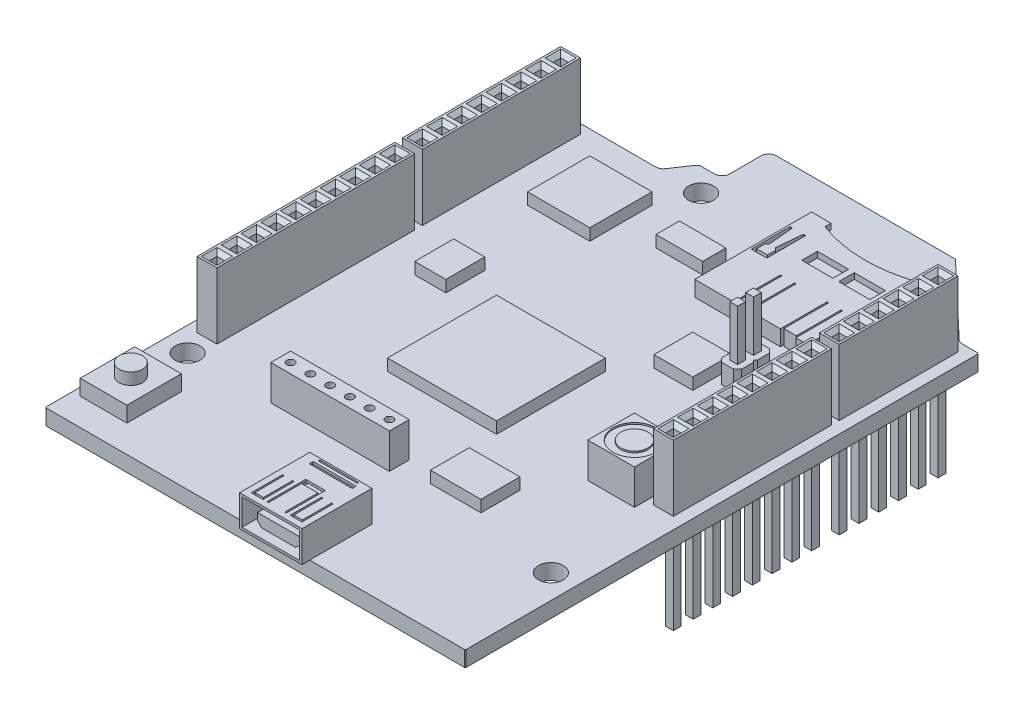
from build123d import *
from OCP.BRepFilletAPI import BRepFilletAPI_MakeChamfer

# Parameters (mm, degrees)
BOSS_EXTRU_1_DEPTH           = 2
ESQUISSE2_W                  = 2.54
ESQUISSE2_H                  = 20.32
ESQUISSE2_W_2                = 1
ESQUISSE2_H_2                = 1
ESQUISSE2_H_3                = 25.4
ESQUISSE2_H_4                = 15.24
BOSS_EXTRU_2_DEPTH           = 8.5
ESQUISSE3_R                  = 1.6
ENL_V_MAT_EXTRU_1_DEPTH      = 93.807596672
ESQUISSE4_W                  = 7.62
ESQUISSE4_H                  = 5.08
ESQUISSE4_W_2                = 1
ESQUISSE4_H_2                = 1
BOSS_EXTRU_3_DEPTH           = 11.5
ESQUISSE5_W                  = 15.24
ESQUISSE5_H                  = 2.54
ESQUISSE5_R                  = 0.5
BOSS_EXTRU_4_DEPTH           = 4.5
ESQUISSE6_W                  = 14
ESQUISSE6_H                  = 14
ESQUISSE6_W_2                = 8
ESQUISSE6_H_2                = 8
ESQUISSE6_W_3                = 6
ESQUISSE6_H_3                = 3
ESQUISSE6_W_4                = 4
ESQUISSE6_H_4                = 5
ESQUISSE6_W_5                = 5
ESQUISSE6_W_6                = 6.5
BOSS_EXTRU_5_DEPTH           = 1.5
ESQUISSE7_W                  = 6
ESQUISSE7_H                  = 7
BOSS_EXTRU_6_DEPTH           = 2
ESQUISSE8_R                  = 1.5
BOSS_EXTRU_7_DEPTH           = 3.5
ESQUISSE9_W                  = 6
ESQUISSE9_H                  = 6
BOSS_EXTRU_8_DEPTH           = 4.5
ESQUISSE10_R                 = 2.75
ESQUISSE10_R_2               = 1.75
ENL_V_MAT_EXTRU_2_DEPTH      = 0.2
ESQUISSE12_W                 = 1
ESQUISSE12_H                 = 1
BOSS_EXTRU_9_DEPTH           = 11.5
BOSS_EXTRU_10_DEPTH          = 2.5
ESQUISSE14_W                 = 1
ESQUISSE14_H                 = 1
BOSS_EXTRU_11_DEPTH          = 9
ESQUISSE15_W                 = 14.5
ESQUISSE15_H                 = 15
BOSS_EXTRU_12_DEPTH          = 2
ESQUISSE16_W                 = 4
ESQUISSE16_H                 = 2
ENL_V_MAT_EXTRU_3_DEPTH      = 94.398340456
ESQUISSE17_W                 = 13
ESQUISSE17_H                 = 1.25
ENL_V_MAT_EXTRU_4_DEPTH      = 11.25
ENL_V_MAT_EXTRU_4_DEPTH_BACK = 87.047951748
ESQUISSE18_W                 = 8
ESQUISSE18_H                 = 9
BOSS_EXTRU_14_DEPTH          = 4
ESQUISSE19_W                 = 5
ESQUISSE19_H                 = 0.2
ESQUISSE19_W_2               = 5.5
ESQUISSE19_H_2               = 0.5
ENL_V_MAT_EXTRU_5_DEPTH      = 0.5
ESQUISSE20_W                 = 7.4
ESQUISSE20_H                 = 3.4
ESQUISSE20_W_2               = 5.4
ESQUISSE20_H_2               = 1.45
ENL_V_MAT_EXTRU_6_DEPTH      = 7.7
ESQUISSE20_2_W               = 7.4
ESQUISSE20_2_H               = 3.4
ENL_V_MAT_EXTRU_7_DEPTH      = 94.130285085
CHANFREIN1_SIZE              = 0.1
CHANFREIN1_SIZE2             = 0.360555128
CHANFREIN2_SIZE              = 0.5
CHANFREIN3_SIZE              = 0.5
CONG_1_R                     = 1


with BuildPart() as part:
    # Esquisse1 → Boss.-Extru.1 (new body)
    with BuildSketch(Plane(origin=(0, 0, 0), x_dir=(1, 0, 0), z_dir=(0, 1, 0))):
        Polygon((0, 0), (54, 0), (54, 66), (51.5, 66), (42, 75), (18, 75), (18, 69), (15, 69), (13, 66), (0, 66), align=None)
    extrude(amount=BOSS_EXTRU_1_DEPTH)

    # Esquisse2 → Boss.-Extru.2 (add)
    with BuildSketch(Plane(origin=(0, 2, 0), x_dir=(1, 0, 0), z_dir=(0, 1, 0))):
        with Locations((2.73, 54.64)):
            Rectangle(ESQUISSE2_W, ESQUISSE2_H)
        with Locations((2.73, 60.99)):
            Rectangle(ESQUISSE2_W_2, ESQUISSE2_H_2, mode=Mode.SUBTRACT)
        with Locations((2.73, 63.53)):
            Rectangle(ESQUISSE2_W_2, ESQUISSE2_H_2, mode=Mode.SUBTRACT)
        with Locations((2.73, 58.45)):
            Rectangle(ESQUISSE2_W_2, ESQUISSE2_H_2, mode=Mode.SUBTRACT)
        with Locations((2.73, 55.91)):
            Rectangle(ESQUISSE2_W_2, ESQUISSE2_H_2, mode=Mode.SUBTRACT)
        with Locations((2.73, 53.37)):
            Rectangle(ESQUISSE2_W_2, ESQUISSE2_H_2, mode=Mode.SUBTRACT)
        with Locations((2.73, 50.83)):
            Rectangle(ESQUISSE2_W_2, ESQUISSE2_H_2, mode=Mode.SUBTRACT)
        with Locations((2.73, 48.29)):
            Rectangle(ESQUISSE2_W_2, ESQUISSE2_H_2, mode=Mode.SUBTRACT)
        with Locations((2.73, 45.75)):
            Rectangle(ESQUISSE2_W_2, ESQUISSE2_H_2, mode=Mode.SUBTRACT)
        with Locations((2.73, 30.78)):
            Rectangle(ESQUISSE2_W, ESQUISSE2_H_3)
        with Locations((2.73, 21.89)):
            Rectangle(ESQUISSE2_W_2, ESQUISSE2_H_2, mode=Mode.SUBTRACT)
        with Locations((2.73, 19.35)):
            Rectangle(ESQUISSE2_W_2, ESQUISSE2_H_2, mode=Mode.SUBTRACT)
        with Locations((2.73, 24.43)):
            Rectangle(ESQUISSE2_W_2, ESQUISSE2_H_2, mode=Mode.SUBTRACT)
        with Locations((2.73, 26.97)):
            Rectangle(ESQUISSE2_W_2, ESQUISSE2_H_2, mode=Mode.SUBTRACT)
        with Locations((2.73, 29.51)):
            Rectangle(ESQUISSE2_W_2, ESQUISSE2_H_2, mode=Mode.SUBTRACT)
        with Locations((2.73, 32.05)):
            Rectangle(ESQUISSE2_W_2, ESQUISSE2_H_2, mode=Mode.SUBTRACT)
        with Locations((2.73, 34.59)):
            Rectangle(ESQUISSE2_W_2, ESQUISSE2_H_2, mode=Mode.SUBTRACT)
        with Locations((2.73, 37.13)):
            Rectangle(ESQUISSE2_W_2, ESQUISSE2_H_2, mode=Mode.SUBTRACT)
        with Locations((2.73, 39.67)):
            Rectangle(ESQUISSE2_W_2, ESQUISSE2_H_2, mode=Mode.SUBTRACT)
        with Locations((2.73, 42.21)):
            Rectangle(ESQUISSE2_W_2, ESQUISSE2_H_2, mode=Mode.SUBTRACT)
        with Locations((51.23, 57.18)):
            Rectangle(ESQUISSE2_W, ESQUISSE2_H_4)
        with Locations((51.23, 60.99)):
            Rectangle(ESQUISSE2_W_2, ESQUISSE2_H_2, mode=Mode.SUBTRACT)
        with Locations((51.23, 63.53)):
            Rectangle(ESQUISSE2_W_2, ESQUISSE2_H_2, mode=Mode.SUBTRACT)
        with Locations((51.23, 58.45)):
            Rectangle(ESQUISSE2_W_2, ESQUISSE2_H_2, mode=Mode.SUBTRACT)
        with Locations((51.23, 55.91)):
            Rectangle(ESQUISSE2_W_2, ESQUISSE2_H_2, mode=Mode.SUBTRACT)
        with Locations((51.23, 53.37)):
            Rectangle(ESQUISSE2_W_2, ESQUISSE2_H_2, mode=Mode.SUBTRACT)
        with Locations((51.23, 50.83)):
            Rectangle(ESQUISSE2_W_2, ESQUISSE2_H_2, mode=Mode.SUBTRACT)
        with Locations((51.23, 38.4)):
            Rectangle(ESQUISSE2_W, ESQUISSE2_H)
        with Locations((51.23, 47.29)):
            Rectangle(ESQUISSE2_W_2, ESQUISSE2_H_2, mode=Mode.SUBTRACT)
        with Locations((51.23, 44.75)):
            Rectangle(ESQUISSE2_W_2, ESQUISSE2_H_2, mode=Mode.SUBTRACT)
        with Locations((51.23, 42.21)):
            Rectangle(ESQUISSE2_W_2, ESQUISSE2_H_2, mode=Mode.SUBTRACT)
        with Locations((51.23, 39.67)):
            Rectangle(ESQUISSE2_W_2, ESQUISSE2_H_2, mode=Mode.SUBTRACT)
        with Locations((51.23, 37.13)):
            Rectangle(ESQUISSE2_W_2, ESQUISSE2_H_2, mode=Mode.SUBTRACT)
        with Locations((51.23, 34.59)):
            Rectangle(ESQUISSE2_W_2, ESQUISSE2_H_2, mode=Mode.SUBTRACT)
        with Locations((51.23, 32.05)):
            Rectangle(ESQUISSE2_W_2, ESQUISSE2_H_2, mode=Mode.SUBTRACT)
        with Locations((51.23, 29.51)):
            Rectangle(ESQUISSE2_W_2, ESQUISSE2_H_2, mode=Mode.SUBTRACT)
    extrude(amount=BOSS_EXTRU_2_DEPTH)

    # Esquisse3 → Enl_v. mat.-Extru.1 (cut, through all)
    with BuildSketch(Plane(origin=(0, 2, 0), x_dir=(1, 0, 0), z_dir=(0, 1, 0))):
        with Locations(Location((18.3, 66, 0), (0, 0, 270))):
            Circle(ESQUISSE3_R)
        with Locations(Location((46.2, 66, 0), (0, 0, 270))):
            Circle(ESQUISSE3_R)
        with Locations(Location((50.9, 14.1, 0), (0, 0, 270))):
            Circle(ESQUISSE3_R)
        with Locations(Location((3.1, 15.2, 0), (0, 0, 270))):
            Circle(ESQUISSE3_R)
    extrude(amount=-ENL_V_MAT_EXTRU_1_DEPTH, mode=Mode.SUBTRACT)

    # Esquisse4 → Boss.-Extru.3 (add)
    with BuildSketch(Plane(origin=(0, 0, 0), x_dir=(1, 0, 0), z_dir=(0, 1, 0))):
        with Locations((26.41, 64.6)):
            Rectangle(ESQUISSE4_W, ESQUISSE4_H)
        with Locations((26.41, 63.33)):
            Rectangle(ESQUISSE4_W_2, ESQUISSE4_H_2, mode=Mode.SUBTRACT)
        with Locations((23.87, 63.33)):
            Rectangle(ESQUISSE4_W_2, ESQUISSE4_H_2, mode=Mode.SUBTRACT)
        with Locations((28.95, 63.33)):
            Rectangle(ESQUISSE4_W_2, ESQUISSE4_H_2, mode=Mode.SUBTRACT)
        with Locations((26.41, 65.87)):
            Rectangle(ESQUISSE4_W_2, ESQUISSE4_H_2, mode=Mode.SUBTRACT)
        with Locations((28.95, 65.87)):
            Rectangle(ESQUISSE4_W_2, ESQUISSE4_H_2, mode=Mode.SUBTRACT)
        with Locations((23.87, 65.87)):
            Rectangle(ESQUISSE4_W_2, ESQUISSE4_H_2, mode=Mode.SUBTRACT)
    extrude(amount=-BOSS_EXTRU_3_DEPTH)

    # Esquisse5 → Boss.-Extru.4 (add)
    with BuildSketch(Plane(origin=(0, 2, 0), x_dir=(1, 0, 0), z_dir=(0, 1, 0))):
        with Locations((21.62, 16.27)):
            Rectangle(ESQUISSE5_W, ESQUISSE5_H)
        with Locations(Location((15.27, 16.27, 0), (0, 0, 270))):
            Circle(ESQUISSE5_R, mode=Mode.SUBTRACT)
        with Locations(Location((17.81, 16.27, 0), (0, 0, 270))):
            Circle(ESQUISSE5_R, mode=Mode.SUBTRACT)
        with Locations(Location((20.35, 16.27, 0), (0, 0, 270))):
            Circle(ESQUISSE5_R, mode=Mode.SUBTRACT)
        with Locations(Location((22.89, 16.27, 0), (0, 0, 270))):
            Circle(ESQUISSE5_R, mode=Mode.SUBTRACT)
        with Locations(Location((25.43, 16.27, 0), (0, 0, 270))):
            Circle(ESQUISSE5_R, mode=Mode.SUBTRACT)
        with Locations(Location((27.97, 16.27, 0), (0, 0, 270))):
            Circle(ESQUISSE5_R, mode=Mode.SUBTRACT)
    extrude(amount=BOSS_EXTRU_4_DEPTH)

    # Esquisse6 → Boss.-Extru.5 (add)
    with BuildSketch(Plane(origin=(0, 2, 0), x_dir=(1, 0, 0), z_dir=(0, 1, 0))):
        with Locations((25, 33)):
            Rectangle(ESQUISSE6_W, ESQUISSE6_H)
        with Locations((12.5, 57.5)):
            Rectangle(ESQUISSE6_W_2, ESQUISSE6_H_2)
        with Locations((24.5, 58.5)):
            Rectangle(ESQUISSE6_W_3, ESQUISSE6_H_3)
        with Locations((11, 41)):
            Rectangle(ESQUISSE6_W_4, ESQUISSE6_H_4)
        with Locations((37.24, 46)):
            Rectangle(ESQUISSE6_W_5, ESQUISSE6_H_4)
        with Locations((36.49, 18.77)):
            Rectangle(ESQUISSE6_W_6, ESQUISSE6_H_4)
    extrude(amount=BOSS_EXTRU_5_DEPTH)

    # Esquisse7 → Boss.-Extru.6 (add)
    with BuildSketch(Plane(origin=(0, 2, 0), x_dir=(1, 0, 0), z_dir=(0, 1, 0))):
        with Locations((4, 7)):
            Rectangle(ESQUISSE7_W, ESQUISSE7_H)
    extrude(amount=BOSS_EXTRU_6_DEPTH)

    # Esquisse8 → Boss.-Extru.7 (add)
    with BuildSketch(Plane(origin=(0, 2, 0), x_dir=(1, 0, 0), z_dir=(0, 1, 0))):
        with Locations(Location((4, 7, 0), (0, 0, 270))):
            Circle(ESQUISSE8_R)
    extrude(amount=BOSS_EXTRU_7_DEPTH)

    # Esquisse9 → Boss.-Extru.8 (add)
    with BuildSketch(Plane(origin=(0, 2, 0), x_dir=(1, 0, 0), z_dir=(0, 1, 0))):
        with Locations((46, 29.74)):
            Rectangle(ESQUISSE9_W, ESQUISSE9_H)
    extrude(amount=BOSS_EXTRU_8_DEPTH)

    # Esquisse10 → Enl_v. mat.-Extru.2 (cut)
    with BuildSketch(Plane(origin=(0, 6.5, 0), x_dir=(1, 0, 0), z_dir=(0, 1, 0))):
        with Locations(Location((46, 29.74, 0), (0, 0, 270))):
            Circle(ESQUISSE10_R)
        with Locations(Location((46, 29.74, 0), (0, 0, 270))):
            Circle(ESQUISSE10_R_2, mode=Mode.SUBTRACT)
    extrude(amount=-ENL_V_MAT_EXTRU_2_DEPTH, mode=Mode.SUBTRACT)

    # Esquisse12 → Boss.-Extru.9 (add)
    with BuildSketch(Plane(origin=(0, 0, 0), x_dir=(1, 0, 0), z_dir=(0, 1, 0))):
        with Locations((2.73, 63.53)):
            Rectangle(ESQUISSE12_W, ESQUISSE12_H)
        with Locations((2.73, 60.99)):
            Rectangle(ESQUISSE12_W, ESQUISSE12_H)
        with Locations((2.73, 58.45)):
            Rectangle(ESQUISSE12_W, ESQUISSE12_H)
        with Locations((2.73, 55.91)):
            Rectangle(ESQUISSE12_W, ESQUISSE12_H)
        with Locations((2.73, 53.37)):
            Rectangle(ESQUISSE12_W, ESQUISSE12_H)
        with Locations((2.73, 50.83)):
            Rectangle(ESQUISSE12_W, ESQUISSE12_H)
        with Locations((2.73, 48.29)):
            Rectangle(ESQUISSE12_W, ESQUISSE12_H)
        with Locations((2.73, 45.75)):
            Rectangle(ESQUISSE12_W, ESQUISSE12_H)
        with Locations((2.73, 42.21)):
            Rectangle(ESQUISSE12_W, ESQUISSE12_H)
        with Locations((2.73, 39.67)):
            Rectangle(ESQUISSE12_W, ESQUISSE12_H)
        with Locations((2.73, 37.13)):
            Rectangle(ESQUISSE12_W, ESQUISSE12_H)
        with Locations((2.73, 34.59)):
            Rectangle(ESQUISSE12_W, ESQUISSE12_H)
        with Locations((2.73, 32.05)):
            Rectangle(ESQUISSE12_W, ESQUISSE12_H)
        with Locations((2.73, 29.51)):
            Rectangle(ESQUISSE12_W, ESQUISSE12_H)
        with Locations((2.73, 26.97)):
            Rectangle(ESQUISSE12_W, ESQUISSE12_H)
        with Locations((2.73, 24.43)):
            Rectangle(ESQUISSE12_W, ESQUISSE12_H)
        with Locations((2.73, 21.89)):
            Rectangle(ESQUISSE12_W, ESQUISSE12_H)
        with Locations((2.73, 19.35)):
            Rectangle(ESQUISSE12_W, ESQUISSE12_H)
        with Locations((51.23, 29.51)):
            Rectangle(ESQUISSE12_W, ESQUISSE12_H)
        with Locations((51.23, 32.05)):
            Rectangle(ESQUISSE12_W, ESQUISSE12_H)
        with Locations((51.23, 34.59)):
            Rectangle(ESQUISSE12_W, ESQUISSE12_H)
        with Locations((51.23, 37.13)):
            Rectangle(ESQUISSE12_W, ESQUISSE12_H)
        with Locations((51.23, 39.67)):
            Rectangle(ESQUISSE12_W, ESQUISSE12_H)
        with Locations((51.23, 42.21)):
            Rectangle(ESQUISSE12_W, ESQUISSE12_H)
        with Locations((51.23, 44.75)):
            Rectangle(ESQUISSE12_W, ESQUISSE12_H)
        with Locations((51.23, 47.29)):
            Rectangle(ESQUISSE12_W, ESQUISSE12_H)
        with Locations((51.23, 50.83)):
            Rectangle(ESQUISSE12_W, ESQUISSE12_H)
        with Locations((51.23, 53.37)):
            Rectangle(ESQUISSE12_W, ESQUISSE12_H)
        with Locations((51.23, 55.91)):
            Rectangle(ESQUISSE12_W, ESQUISSE12_H)
        with Locations((51.23, 58.45)):
            Rectangle(ESQUISSE12_W, ESQUISSE12_H)
        with Locations((51.23, 60.99)):
            Rectangle(ESQUISSE12_W, ESQUISSE12_H)
        with Locations((51.23, 63.53)):
            Rectangle(ESQUISSE12_W, ESQUISSE12_H)
    extrude(amount=-BOSS_EXTRU_9_DEPTH)

    # Esquisse13 → Boss.-Extru.10 (add)
    with BuildSketch(Plane(origin=(0, 2, 0), x_dir=(1, 0, 0), z_dir=(0, 1, 0))):
        Polygon((40.96, 50.58), (40.46, 50.08), (40.46, 48.54), (40.71, 48.29), (40.46, 48.04), (40.46, 46.5), (40.96, 46), (42.5, 46), (43, 46.5), (43, 48.04), (42.75, 48.29), (43, 48.54), (43, 50.08), (42.5, 50.58), align=None)
    extrude(amount=BOSS_EXTRU_10_DEPTH)

    # Esquisse14 → Boss.-Extru.11 (add)
    with BuildSketch(Plane(origin=(0, 2, 0), x_dir=(1, 0, 0), z_dir=(0, 1, 0))):
        with Locations((41.73, 49.31)):
            Rectangle(ESQUISSE14_W, ESQUISSE14_H)
        with Locations((41.73, 47.27)):
            Rectangle(ESQUISSE14_W, ESQUISSE14_H)
    extrude(amount=BOSS_EXTRU_11_DEPTH)

    # Esquisse15 → Boss.-Extru.12 (add)
    with BuildSketch(Plane(origin=(0, 2, 0), x_dir=(1, 0, 0), z_dir=(0, 1, 0))):
        with Locations((36.75, 61.5)):
            Rectangle(ESQUISSE15_W, ESQUISSE15_H)
    extrude(amount=BOSS_EXTRU_12_DEPTH)

    # Esquisse16 → Enl_v. mat.-Extru.3 (cut, through all)
    with BuildSketch(Plane(origin=(0, 2, 0), x_dir=(1, 0, 0), z_dir=(0, 1, 0))):
        Polygon((30.05, 66), (30.35, 62.7), (30.05, 62.4), (30.05, 61.4), (31.45, 61.4), (31.45, 62.4), (31.15, 62.7), (31.45, 66), (31.75, 66), (31.75, 61), (29.75, 61), (29.75, 66), align=None)
        with BuildLine():
            Line((32, 68.225), (32, 69))
            Line((32, 69), (44, 69))
            Line((44, 69), (44, 68))
            ThreePointArc((44, 68), (37.98060858, 67.078290923), (32, 68.225))
        make_face()
        with Locations((36.25, 64)):
            Rectangle(ESQUISSE16_W, ESQUISSE16_H)
        with Locations((41, 64)):
            Rectangle(ESQUISSE16_W, ESQUISSE16_H)
        Polygon((34.5, 60), (34.7, 60), (34.7, 54.25), (36.3, 54.25), (36.3, 60), (36.5, 60), (36.5, 54), (34.5, 54), align=None)
        Polygon((40.5, 60), (40.7, 60), (40.7, 54.25), (42.3, 54.25), (42.3, 60), (42.5, 60), (42.5, 54), (40.5, 54), align=None)
    extrude(amount=ENL_V_MAT_EXTRU_3_DEPTH, mode=Mode.SUBTRACT)

    # Esquisse17 → Enl_v. mat.-Extru.4 (cut, two sides)
    with BuildSketch(Plane.XY.offset(-66)) as enl_v_mat_extru_4_sk:
        with Locations((36.75, 2.625)):
            Rectangle(ESQUISSE17_W, ESQUISSE17_H)
    extrude(amount=ENL_V_MAT_EXTRU_4_DEPTH, mode=Mode.SUBTRACT)
    extrude(enl_v_mat_extru_4_sk.sketch, amount=-ENL_V_MAT_EXTRU_4_DEPTH_BACK, mode=Mode.SUBTRACT)

    # Esquisse18 → Boss.-Extru.14 (add)
    with BuildSketch(Plane(origin=(0, 2, 0), x_dir=(1, 0, 0), z_dir=(0, 1, 0))):
        with Locations((30, 3.5)):
            Rectangle(ESQUISSE18_W, ESQUISSE18_H)
    extrude(amount=BOSS_EXTRU_14_DEPTH)

    # Esquisse19 → Enl_v. mat.-Extru.5 (cut)
    with BuildSketch(Plane(origin=(0, 6, 0), x_dir=(1, 0, 0), z_dir=(0, 1, 0))):
        with Locations((30, 7.7)):
            Rectangle(ESQUISSE19_W, ESQUISSE19_H)
        with Locations((30, 6.95)):
            Rectangle(ESQUISSE19_W_2, ESQUISSE19_H_2)
        Polygon((31.75, 3.75), (31.95, 3.75), (31.95, 0), (33.05, 0), (33.05, 3.75), (33.25, 3.75), (33.25, -0.25), (31.75, -0.25), align=None)
        Polygon((26.75, 3.75), (26.95, 3.75), (26.95, 0), (28.05, 0), (28.05, 3.75), (28.25, 3.75), (28.25, -0.25), (26.75, -0.25), align=None)
        Polygon((31.05, -0.25), (31.25, -0.25), (31.25, 4.75), (28.75, 4.75), (28.75, -0.25), (28.95, -0.25), (28.95, 4), (31.05, 4), align=None)
    extrude(amount=-ENL_V_MAT_EXTRU_5_DEPTH, mode=Mode.SUBTRACT)

    # Esquisse20 → Enl_v. mat.-Extru.6 (cut)
    with BuildSketch(Plane.XY):
        with Locations((30, 4)):
            Rectangle(ESQUISSE20_W, ESQUISSE20_H)
        with Locations((30, 3.225)):
            Rectangle(ESQUISSE20_W_2, ESQUISSE20_H_2, mode=Mode.SUBTRACT)
    extrude(amount=-ENL_V_MAT_EXTRU_6_DEPTH, mode=Mode.SUBTRACT)

    # Esquisse20_2 → Enl_v. mat.-Extru.7 (cut, through all)
    with BuildSketch(Plane.XY):
        with Locations((30, 4)):
            Rectangle(ESQUISSE20_2_W, ESQUISSE20_2_H)
    extrude(amount=ENL_V_MAT_EXTRU_7_DEPTH, mode=Mode.SUBTRACT)

    # Chanfrein1: one chamfer whose edges measure the first distance from different faces: ONE call of the kernel's chamfer builder (chamfer() names one face for all edges)
    chanfrein1_edges_1 = [part.edges().sort_by_distance(p)[0] for p in [
        (54, 1, 0),
        (54, 1, -66),
        (0, 1, -66),
        (0, 1, 0),
    ]]
    chanfrein1_edges_2 = [part.edges().sort_by_distance(p)[0] for p in [
        (15, 1, -69),
    ]]
    chanfrein1_side_2 = [part.faces().sort_by_distance(p)[0] for p in [
        (16.5, 1, -69),
    ]]
    chanfrein1 = BRepFilletAPI_MakeChamfer(part.part.solid().wrapped)
    for e in chanfrein1_edges_1:
        chanfrein1.Add(CHANFREIN1_SIZE, e.wrapped)
    for e in chanfrein1_edges_2:
        chanfrein1.Add(CHANFREIN1_SIZE, CHANFREIN1_SIZE2, e.wrapped, chanfrein1_side_2[0].wrapped)  # the first distance lies on this face
    add(Compound.cast(chanfrein1.Shape()), mode=Mode.REPLACE)

    # Chanfrein2
    chanfrein2_edges = [part.edges().sort_by_distance(p)[0] for p in [
        (3.23, 10.5, -19.35),
        (2.73, 10.5, -19.85),
        (2.23, 10.5, -19.35),
        (2.73, 10.5, -18.85),
        (3.23, 10.5, -21.89),
        (2.73, 10.5, -22.39),
        (2.23, 10.5, -21.89),
        (2.73, 10.5, -21.39),
        (3.23, 10.5, -24.43),
        (2.73, 10.5, -24.93),
        (2.23, 10.5, -24.43),
        (2.73, 10.5, -23.93),
        (3.23, 10.5, -26.97),
        (2.73, 10.5, -27.47),
        (2.23, 10.5, -26.97),
        (2.73, 10.5, -26.47),
        (3.23, 10.5, -29.51),
        (2.73, 10.5, -30.01),
        (2.23, 10.5, -29.51),
        (2.73, 10.5, -29.01),
        (3.23, 10.5, -32.05),
        (2.73, 10.5, -32.55),
        (2.23, 10.5, -32.05),
        (2.73, 10.5, -31.55),
        (3.23, 10.5, -34.59),
        (2.73, 10.5, -35.09),
        (2.23, 10.5, -34.59),
        (2.73, 10.5, -34.09),
        (3.23, 10.5, -37.13),
        (2.73, 10.5, -37.63),
        (2.23, 10.5, -37.13),
        (2.73, 10.5, -36.63),
        (3.23, 10.5, -39.67),
        (2.73, 10.5, -40.17),
        (2.23, 10.5, -39.67),
        (2.73, 10.5, -39.17),
        (3.23, 10.5, -42.21),
        (2.73, 10.5, -42.71),
        (2.23, 10.5, -42.21),
        (2.73, 10.5, -41.71),
        (51.73, 10.5, -63.53),
        (51.23, 10.5, -64.03),
        (50.73, 10.5, -63.53),
        (51.23, 10.5, -63.03),
        (51.73, 10.5, -60.99),
        (51.23, 10.5, -61.49),
        (50.73, 10.5, -60.99),
        (51.23, 10.5, -60.49),
        (51.73, 10.5, -58.45),
        (51.23, 10.5, -58.95),
        (50.73, 10.5, -58.45),
        (51.23, 10.5, -57.95),
        (51.73, 10.5, -55.91),
        (51.23, 10.5, -56.41),
        (50.73, 10.5, -55.91),
        (51.23, 10.5, -55.41),
        (51.73, 10.5, -53.37),
        (51.23, 10.5, -53.87),
        (50.73, 10.5, -53.37),
        (51.23, 10.5, -52.87),
        (51.73, 10.5, -50.83),
        (51.23, 10.5, -51.33),
        (50.73, 10.5, -50.83),
        (51.23, 10.5, -50.33),
        (51.73, 10.5, -47.29),
        (51.23, 10.5, -47.79),
        (50.73, 10.5, -47.29),
        (51.23, 10.5, -46.79),
        (51.73, 10.5, -44.75),
        (51.23, 10.5, -45.25),
        (50.73, 10.5, -44.75),
        (51.23, 10.5, -44.25),
        (51.73, 10.5, -42.21),
        (51.23, 10.5, -42.71),
        (50.73, 10.5, -42.21),
        (51.23, 10.5, -41.71),
        (51.73, 10.5, -39.67),
        (51.23, 10.5, -40.17),
        (50.73, 10.5, -39.67),
        (51.23, 10.5, -39.17),
        (51.73, 10.5, -37.13),
        (51.23, 10.5, -37.63),
        (50.73, 10.5, -37.13),
        (51.23, 10.5, -36.63),
        (51.73, 10.5, -34.59),
        (51.23, 10.5, -35.09),
        (50.73, 10.5, -34.59),
        (51.23, 10.5, -34.09),
        (51.73, 10.5, -32.05),
        (51.23, 10.5, -32.55),
        (50.73, 10.5, -32.05),
        (51.23, 10.5, -31.55),
        (51.73, 10.5, -29.51),
        (51.23, 10.5, -30.01),
        (50.73, 10.5, -29.51),
        (51.23, 10.5, -29.01),
        (23.87, -11.5, -63.83),
        (23.37, -11.5, -63.33),
        (23.87, -11.5, -62.83),
        (24.37, -11.5, -63.33),
        (26.41, -11.5, -63.83),
        (25.91, -11.5, -63.33),
        (26.41, -11.5, -62.83),
        (26.91, -11.5, -63.33),
        (28.95, -11.5, -63.83),
        (28.45, -11.5, -63.33),
        (28.95, -11.5, -62.83),
        (29.45, -11.5, -63.33),
        (26.41, -11.5, -66.37),
        (25.91, -11.5, -65.87),
        (26.41, -11.5, -65.37),
        (26.91, -11.5, -65.87),
        (28.95, -11.5, -66.37),
        (28.45, -11.5, -65.87),
        (28.95, -11.5, -65.37),
        (29.45, -11.5, -65.87),
        (23.87, -11.5, -66.37),
        (23.37, -11.5, -65.87),
        (23.87, -11.5, -65.37),
        (24.37, -11.5, -65.87),
        (3.23, 10.5, -63.53),
        (2.73, 10.5, -64.03),
        (2.23, 10.5, -63.53),
        (2.73, 10.5, -63.03),
        (3.23, 10.5, -60.99),
        (2.73, 10.5, -61.49),
        (2.23, 10.5, -60.99),
        (2.73, 10.5, -60.49),
        (3.23, 10.5, -58.45),
        (2.73, 10.5, -58.95),
        (2.23, 10.5, -58.45),
        (2.73, 10.5, -57.95),
        (3.23, 10.5, -55.91),
        (2.73, 10.5, -56.41),
        (2.23, 10.5, -55.91),
        (2.73, 10.5, -55.41),
        (3.23, 10.5, -53.37),
        (2.73, 10.5, -53.87),
        (2.23, 10.5, -53.37),
        (2.73, 10.5, -52.87),
        (3.23, 10.5, -50.83),
        (2.73, 10.5, -51.33),
        (2.23, 10.5, -50.83),
        (2.73, 10.5, -50.33),
        (3.23, 10.5, -48.29),
        (2.73, 10.5, -48.79),
        (2.23, 10.5, -48.29),
        (2.73, 10.5, -47.79),
        (3.23, 10.5, -45.75),
        (2.73, 10.5, -46.25),
        (2.23, 10.5, -45.75),
        (2.73, 10.5, -45.25),
    ]]
    chamfer(chanfrein2_edges, length=CHANFREIN2_SIZE)

    # Chanfrein3
    chanfrein3_edges = [part.edges().sort_by_distance(p)[0] for p in [
        (27.3, 2.5, -3.85),
        (32.7, 2.5, -3.85),
    ]]
    chamfer(chanfrein3_edges, length=CHANFREIN3_SIZE)

    # Cong_1
    cong_1_edges = [part.edges().sort_by_distance(p)[0] for p in [
        (51.5, 1, -66),
        (18, 1, -75),
        (18, 1, -69),
        (13, 1, -66),
    ]]
    fillet(cong_1_edges, radius=CONG_1_R)


solid = part.part
